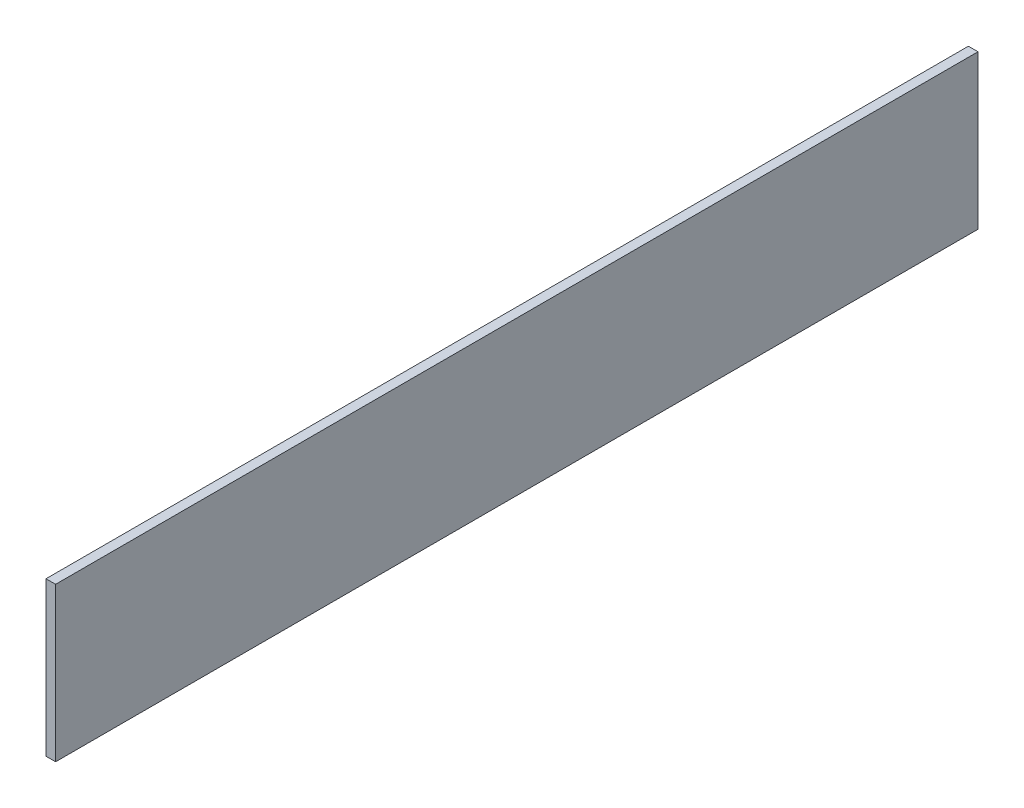
from build123d import *

# Parameters (mm, degrees)
SKETCH1_W           = 152.4
SKETCH1_H           = 25.4
BOSS_EXTRUDE1_DEPTH = 1.5875


with BuildPart() as part:
    # Sketch1 → Boss-Extrude1 (new body)
    with BuildSketch(Plane(origin=(0, 0, 0), x_dir=(0, 0, -1), z_dir=(1, 0, 0))):
        with Locations((76.2, 12.7)):
            Rectangle(SKETCH1_W, SKETCH1_H)
    extrude(amount=BOSS_EXTRUDE1_DEPTH)


solid = part.part
